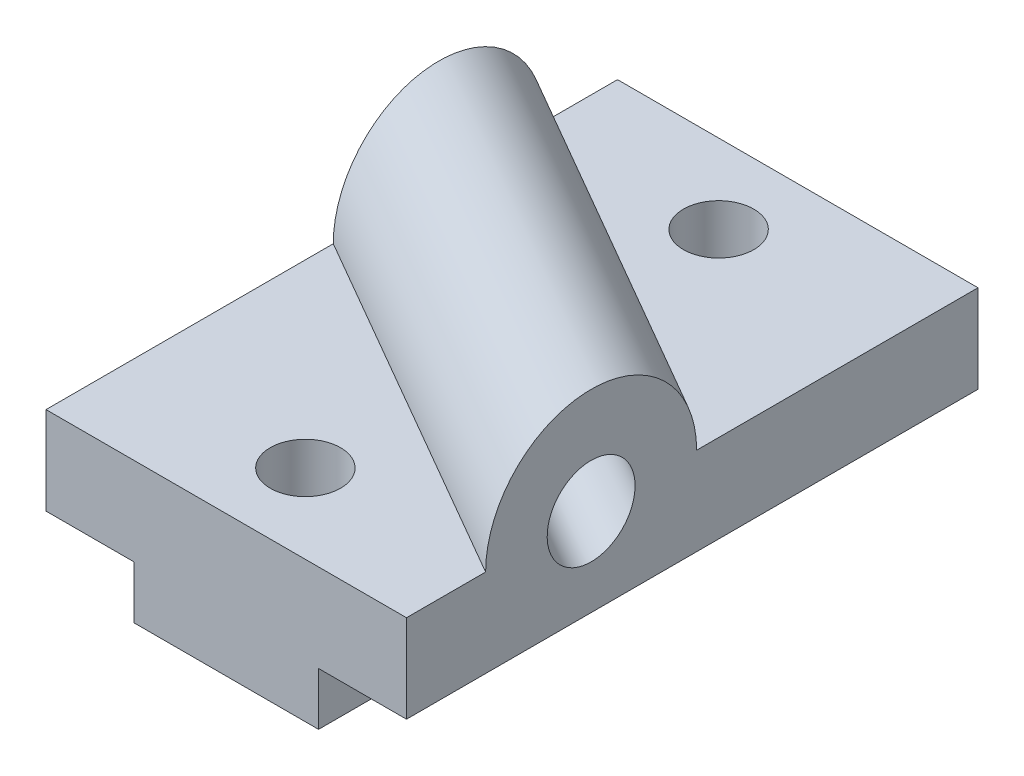
from build123d import *

# Parameters (mm, degrees)
BOSS_EXTRUDE1_DEPTH = 51.59375
BOSS_EXTRUDE2_DEPTH = 75.156571292
SKETCH5_R           = 7.9375
CUT_EXTRUDE1_DEPTH  = 109.930311747
SKETCH6_R           = 6.35
CUT_EXTRUDE2_DEPTH  = 76.68979598


with BuildPart() as part:
    # Sketch2 → Boss-Extrude1 (new, symmetric)
    with BuildSketch(Plane.XY):
        Polygon((0, 9.525), (-15.875, 9.525), (-15.875, 25.4), (49.2125, 25.4), (49.2125, 9.525), (33.3375, 9.525), (33.3375, 0), (0, 0), align=None)
    extrude(amount=BOSS_EXTRUDE1_DEPTH, both=True)

    # Sketch3 → Boss-Extrude2 (add, along a direction that is not the sketch's normal)
    with BuildSketch(Plane(origin=(49.2125, 0, 0), x_dir=(0, 0, -1), z_dir=(1, 0, 0))):
        with BuildLine():
            Line((0.79375, 25.4), (-37.30625, 25.4))
            ThreePointArc((-37.30625, 25.4), (-18.25625, 44.45), (0.79375, 25.4))
        make_face()
    extrude(amount=-BOSS_EXTRUDE2_DEPTH, dir=(0.86602540378444, 0, 0.49999999999999767))

    # Sketch5 → Cut-Extrude1 (cut, through all, along a direction that is not the sketch's normal)
    with BuildSketch(Plane(origin=(49.2125, 0, 0), x_dir=(0, 0, -1), z_dir=(1, 0, 0))):
        with Locations((-18.25625, 25.4)):
            Circle(SKETCH5_R)
    extrude(amount=-CUT_EXTRUDE1_DEPTH, dir=(0.86602540378444, 0, 0.49999999999999767), mode=Mode.SUBTRACT)

    # Sketch6 → Cut-Extrude2 (cut, through all)
    with BuildSketch(Plane(origin=(0, 25.4, 0), x_dir=(1, 0, 0), z_dir=(0, 1, 0))):
        with Locations(Location((16.66875, -37.30625, 0), (0, 0, 180))):
            Circle(SKETCH6_R)
        with Locations(Location((16.66875, 37.30625, 0), (0, 0, 180))):
            Circle(SKETCH6_R)
    extrude(amount=-CUT_EXTRUDE2_DEPTH, mode=Mode.SUBTRACT)


solid = part.part
